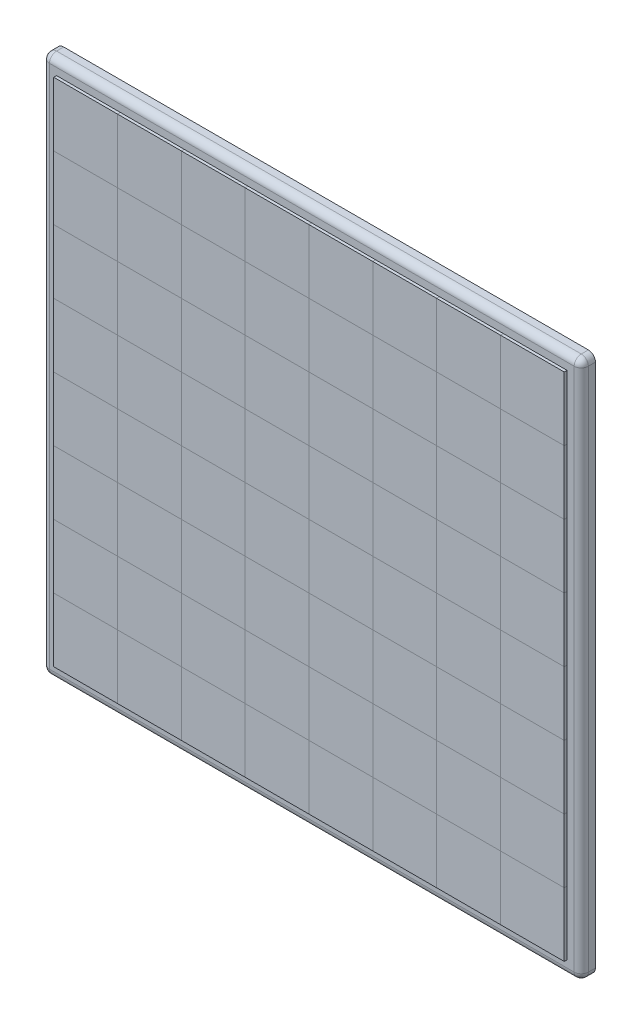
from build123d import *

# Parameters (mm, degrees)
SKETCH1_W            = 380
SKETCH1_H            = 380
BOSS_EXTRUDE1_DEPTH  = 10
SKETCH2_W            = 45
SKETCH2_H            = 45
BOSS_EXTRUDE2_DEPTH  = 2
LPATTERN1_COUNT      = 4
LPATTERN1_PITCH      = 90
LPATTERN1_COUNT_DIR2 = 4
LPATTERN1_PITCH_DIR2 = 90
SKETCH3_W            = 45
SKETCH3_H            = 45
BOSS_EXTRUDE4_DEPTH  = 2
LPATTERN2_COUNT      = 4
LPATTERN2_PITCH      = 90
LPATTERN2_COUNT_DIR2 = 4
LPATTERN2_PITCH_DIR2 = 90
SKETCH4_W            = 45
SKETCH4_H            = 45
BOSS_EXTRUDE5_DEPTH  = 2
SKETCH5_W            = 45
SKETCH5_H            = 45
BOSS_EXTRUDE6_DEPTH  = 2
LPATTERN4_COUNT      = 4
LPATTERN4_PITCH      = 90
LPATTERN4_COUNT_DIR2 = 4
LPATTERN4_PITCH_DIR2 = 90
LPATTERN5_COUNT      = 4
LPATTERN5_PITCH      = 90
LPATTERN5_COUNT_DIR2 = 4
LPATTERN5_PITCH_DIR2 = 90
FILLET1_R            = 5


with BuildPart() as part:
    # Sketch1 → Boss-Extrude1 (new body)
    with BuildSketch(Plane.XY):
        Rectangle(SKETCH1_W, SKETCH1_H)
    extrude(amount=BOSS_EXTRUDE1_DEPTH)

    # Sketch2 → Boss-Extrude2 (add)
    with BuildSketch(Plane.XY.offset(10)):
        with Locations((-157.5, 157.5)):
            Rectangle(SKETCH2_W, SKETCH2_H)
    boss_extrude2 = extrude(amount=BOSS_EXTRUDE2_DEPTH)

    # LPattern1: Boss-Extrude2 4 × 4
    with Locations(*[(i * LPATTERN1_PITCH, -j * LPATTERN1_PITCH_DIR2, 0) for i in range(LPATTERN1_COUNT) for j in range(LPATTERN1_COUNT_DIR2) if (i, j) != (0, 0)]):
        add(boss_extrude2)

    # Fillet1
    fillet1_edges = [part.edges().sort_by_distance(p)[0] for p in [
        (-190, 0, 10),
        (0, -190, 10),
        (190, 0, 10),
        (190, -190, 5),
        (-190, -190, 5),
        (-190, 190, 5),
        (190, 190, 5),
        (0, 190, 10),
    ]]
    fillet(fillet1_edges, radius=FILLET1_R)


with BuildPart() as body_2:
    # Sketch3 → Boss-Extrude4 (new body)
    with BuildSketch(Plane.XY.offset(10)):
        with Locations((-112.5, 157.5)):
            Rectangle(SKETCH3_W, SKETCH3_H)
    boss_extrude4 = extrude(amount=BOSS_EXTRUDE4_DEPTH)


with BuildPart() as lpattern2_1:
    # LPattern2: Boss-Extrude4 4 × 4
    with Locations(*[(i * LPATTERN2_PITCH, -j * LPATTERN2_PITCH_DIR2, 0) for i in range(LPATTERN2_COUNT) for j in range(LPATTERN2_COUNT_DIR2) if (i, j) != (0, 0)]):
        add(boss_extrude4)


with BuildPart() as body_18:
    # Sketch4 → Boss-Extrude5 (new body)
    with BuildSketch(Plane.XY.offset(10)):
        with Locations((-157.5, 112.5)):
            Rectangle(SKETCH4_W, SKETCH4_H)
    boss_extrude5 = extrude(amount=BOSS_EXTRUDE5_DEPTH)


with BuildPart() as body_19:
    # Sketch5 → Boss-Extrude6 (new body)
    with BuildSketch(Plane.XY.offset(10)):
        with Locations((-112.5, 112.5)):
            Rectangle(SKETCH5_W, SKETCH5_H)
    boss_extrude6 = extrude(amount=BOSS_EXTRUDE6_DEPTH)


with BuildPart() as lpattern4_1:
    # LPattern4: Boss-Extrude5 4 × 4
    with Locations(*[(j * LPATTERN4_PITCH_DIR2, -i * LPATTERN4_PITCH, 0) for i in range(LPATTERN4_COUNT) for j in range(LPATTERN4_COUNT_DIR2) if (i, j) != (0, 0)]):
        add(boss_extrude5)


with BuildPart() as lpattern5_1:
    # LPattern5: Boss-Extrude6 4 × 4
    with Locations(*[(i * LPATTERN5_PITCH, -j * LPATTERN5_PITCH_DIR2, 0) for i in range(LPATTERN5_COUNT) for j in range(LPATTERN5_COUNT_DIR2) if (i, j) != (0, 0)]):
        add(boss_extrude6)


solid = Compound([part.part, body_2.part, lpattern2_1.part, body_18.part, body_19.part, lpattern4_1.part, lpattern5_1.part])
